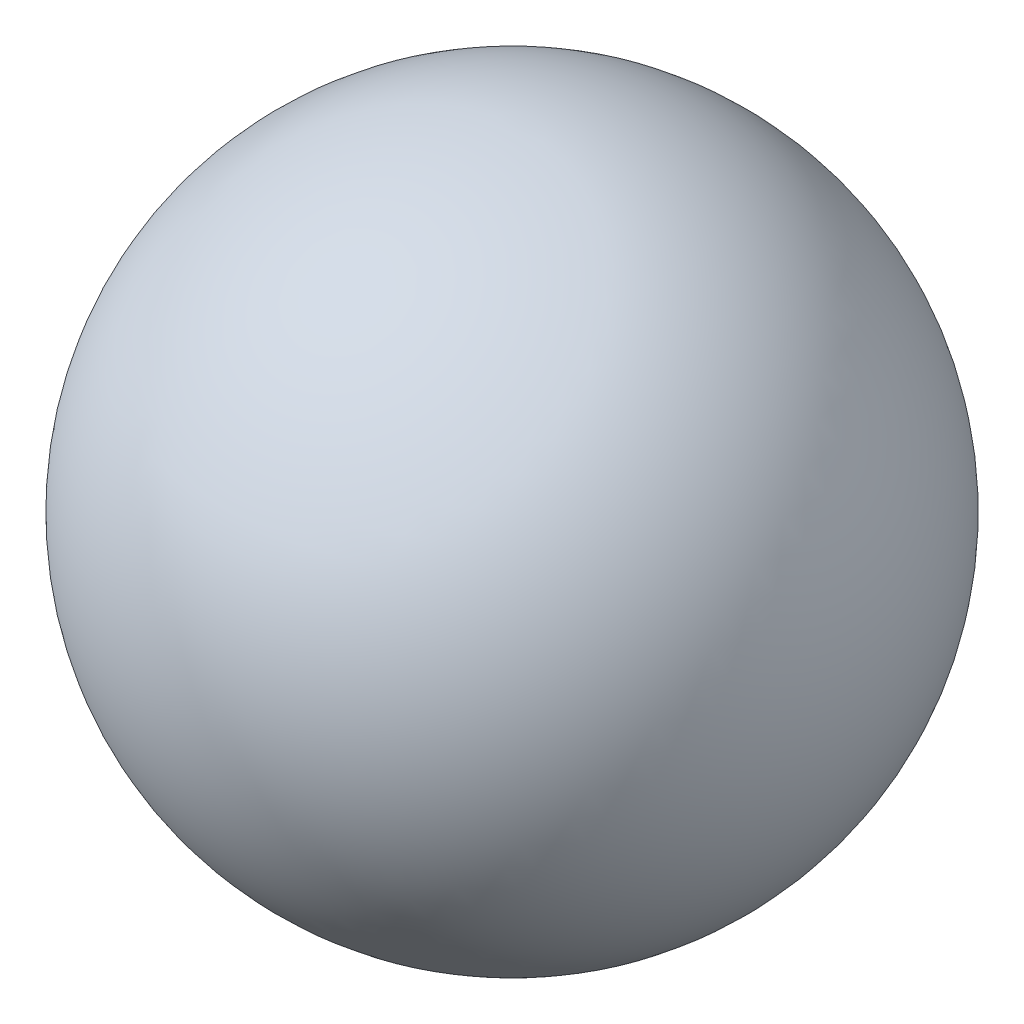
from build123d import *


with BuildPart() as part:
    # Sketch1 → Revolve1 (revolve)
    with BuildSketch(Plane.XY):
        with BuildLine():
            Line((0, 21.5), (0, 16.75))
            Line((0, 16.75), (0, -16.75))
            Line((0, -16.75), (0, -21.5))
            ThreePointArc((0, -21.5), (-21.5, 0), (0, 21.5))
        make_face()
    revolve(axis=Axis((0, 105.084210526, 0), (0, -1, 0)))


solid = part.part
